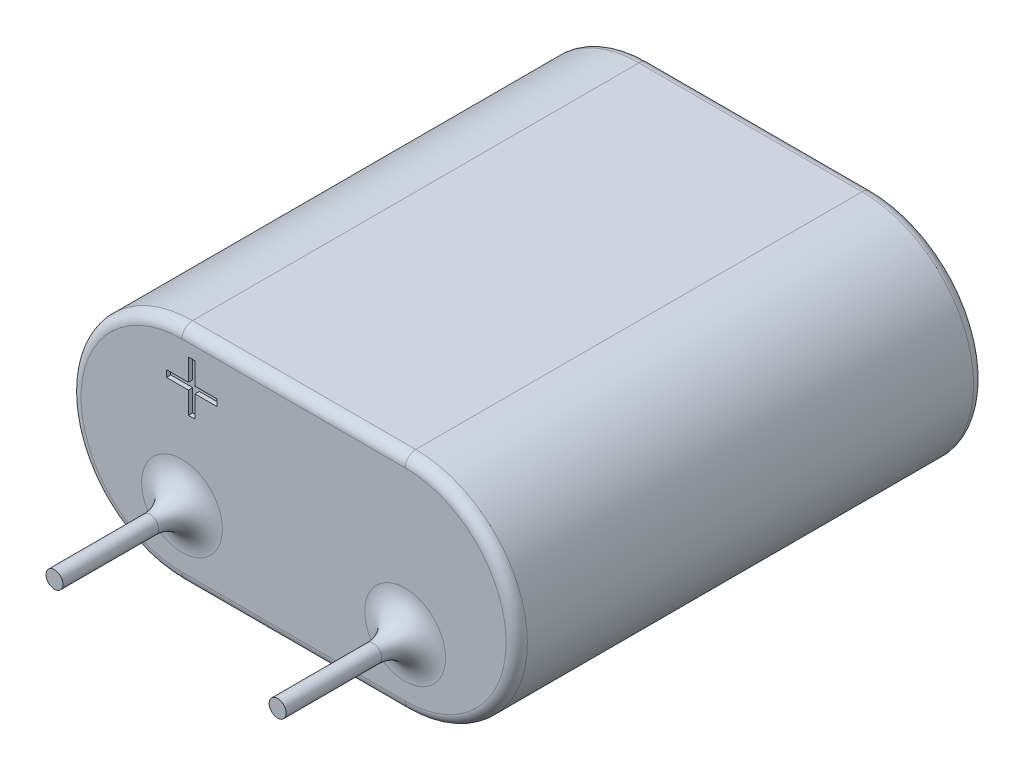
from build123d import *

# Parameters (mm, degrees)
BOSS_EXTRUDE1_DEPTH = 22
SKETCH2_R           = 0.4
FILLET1_R           = 1.5
FILLET2_R           = 0.5
CUT_EXTRUDE1_DEPTH  = 0.2


with BuildPart() as part:
    # Sketch1 → Boss-Extrude1 (new body)
    with BuildSketch(Plane.XY):
        with BuildLine():
            Line((0, 5.25), (10.5, 5.25))
            ThreePointArc((10.5, 5.25), (15.75, 0), (10.5, -5.25))
            Line((10.5, -5.25), (0, -5.25))
            ThreePointArc((0, -5.25), (-5.25, 0), (0, 5.25))
        make_face()
    extrude(amount=-BOSS_EXTRUDE1_DEPTH)

    # Sweep1: sweep along a path in Sketch3
    with BuildLine(Plane.YZ) as sweep1_path:
        Line((-2.05, 0), (-2.05, 6))
    # Sketch2 → Sweep1 (sweep)
    with BuildSketch(Plane.XY):
        with Locations((0, -2.05)):
            Circle(SKETCH2_R)
        with Locations((10.5, -2.05)):
            Circle(SKETCH2_R)
    sweep(path=sweep1_path.line)

    # Fillet1
    fillet1_edges = [part.edges().sort_by_distance(p)[0] for p in [
        (10.1, -2.05, 0),
        (-0.4, -2.05, 0),
    ]]
    fillet(fillet1_edges, radius=FILLET1_R)

    # Fillet2
    fillet2_edges = [part.edges().sort_by_distance(p)[0] for p in [
        (5.25, -5.25, -22),
        (15.75, 0, -22),
        (5.25, 5.25, -22),
        (-5.25, 0, -22),
        (5.25, 5.25, 0),
        (15.75, 0, 0),
        (5.25, -5.25, 0),
        (-5.25, 0, 0),
    ]]
    fillet(fillet2_edges, radius=FILLET2_R)

    # Sketch4 → Cut-Extrude1 (cut)
    with BuildSketch(Plane.XY):
        Polygon((0.301282051, 3.134615385), (0.301282051, 4.166666667), (0.615384615, 4.166666667), (0.615384615, 3.134615385), (1.647435897, 3.134615385), (1.647435897, 2.820512821), (0.615384615, 2.820512821), (0.615384615, 1.788461538), (0.301282051, 1.788461538), (0.301282051, 2.820512821), (-0.730769231, 2.820512821), (-0.730769231, 3.134615385), align=None)
    extrude(amount=-CUT_EXTRUDE1_DEPTH, mode=Mode.SUBTRACT)


solid = part.part
